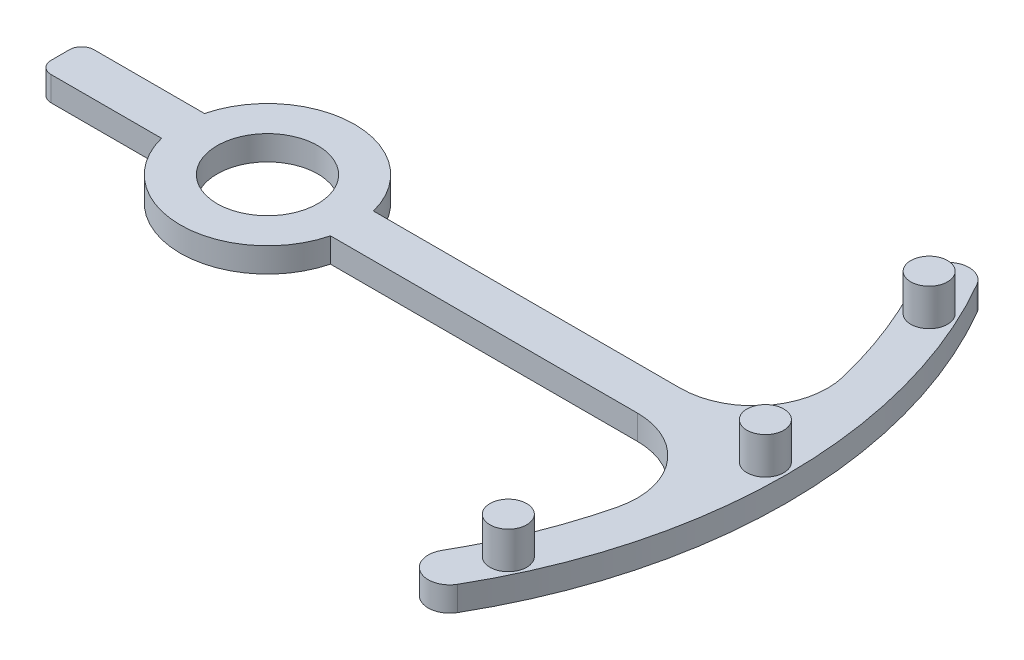
from build123d import *

# Parameters (mm, degrees)
SKETCH1_R           = 4.1
BOSS_EXTRUDE1_DEPTH = 2
SKETCH2_R           = 1.5
BOSS_EXTRUDE2_DEPTH = 3


with BuildPart() as part:
    # Sketch1 → Boss-Extrude1 (new body)
    with BuildSketch(Plane(origin=(0, 0, 0), x_dir=(1, 0, 0), z_dir=(0, 1, 0))):
        with BuildLine():
            Line((6.880964228, 1.749997239), (31.880964166, 1.749997239))
            ThreePointArc((31.880964166, 1.749997239), (36.598148239, 4.042144166), (37.711172654, 9.167272434))
            ThreePointArc((37.711172654, 9.167272434), (36.026057764, 14.43241452), (33.609947488, 19.40471223))
            ThreePointArc((33.609947488, 19.40471223), (34.250491945, 21.795256686), (36.641036401, 21.15471223))
            ThreePointArc((36.641036401, 21.15471223), (42.309424459, 0), (36.641036401, -21.15471223))
            ThreePointArc((36.641036401, -21.15471223), (34.250491945, -21.795256686), (33.609947488, -19.40471223))
            ThreePointArc((33.609947488, -19.40471223), (36.026056514, -14.432417639), (37.711171067, -9.167278965))
            ThreePointArc((37.711171067, -9.167278965), (36.598147218, -4.042150095), (31.880962823, -1.750002761))
            Line((31.880962823, -1.750002761), (6.880962823, -1.750002761))
            ThreePointArc((6.880962823, -1.750002761), (-0.000729594, -7.100011163), (-6.881322337, -1.748588554))
            Line((-6.881322337, -1.748588554), (-15.881322337, -1.748588554))
            ThreePointArc((-15.881322337, -1.748588554), (-16.588429118, -1.455695335), (-16.881322337, -0.748588554))
            Line((-16.881322337, -0.748588554), (-16.881322337, 0.748588554))
            ThreePointArc((-16.881322337, 0.748588554), (-16.588429118, 1.455695335), (-15.881322337, 1.748588554))
            Line((-15.881322337, 1.748588554), (-6.881322337, 1.748588554))
            ThreePointArc((-6.881322337, 1.748588554), (-0.000726746, 7.100011163), (6.880964228, 1.749997239))
        make_face()
        Circle(SKETCH1_R, mode=Mode.SUBTRACT)
    extrude(amount=BOSS_EXTRUDE1_DEPTH)

    # Sketch2 → Boss-Extrude2 (add)
    with BuildSketch(Plane(origin=(0, 2, 0), x_dir=(1, 0, 0), z_dir=(0, 1, 0))):
        with Locations((36.759322225, 17.141153462)):
            Circle(SKETCH2_R)
        with Locations((40.559424459, 0)):
            Circle(SKETCH2_R)
        with Locations((36.759322225, -17.141153462)):
            Circle(SKETCH2_R)
    extrude(amount=BOSS_EXTRUDE2_DEPTH)


solid = part.part
